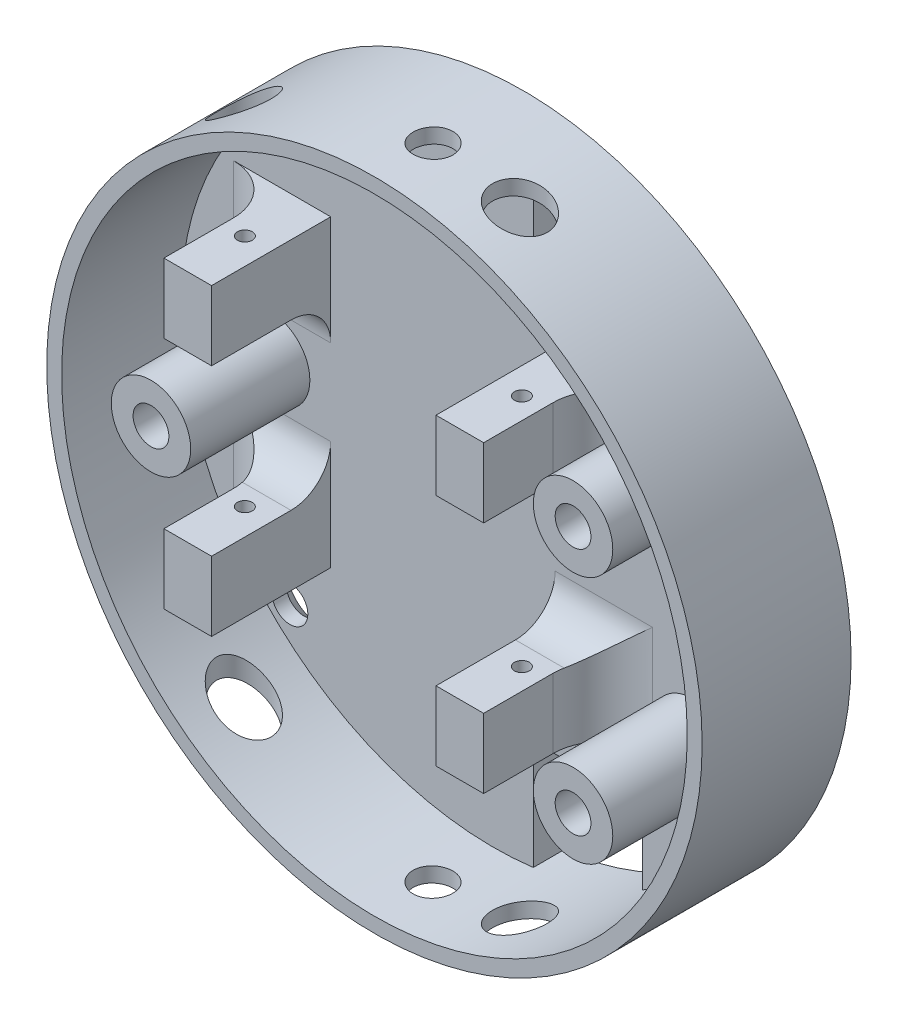
from build123d import *

# Parameters (mm, degrees)
CROQUIS1_R                                           = 33
SALIENTE_EXTRUIR1_DEPTH                              = 3
SALIENTE_EXTRUIR2_DEPTH                              = 12
CORTAR_EXTRUIR1_REACH                                = 62.389
CROQUIS3_R                                           = 0.7500000000000021
CROQUIS3_R_2                                         = 0.7500000000000004
CROQUIS6_R                                           = 1.8000000000000005
CROQUIS6_R_2                                         = 1.8000000000000007
CROQUIS6_R_3                                         = 1.8000000000011862
CROQUIS6_R_4                                         = 1.8000000000016134
CROQUIS6_R_5                                         = 1.8000000000006053
CORTAR_EXTRUIR4_DEPTH                                = 3
CROQUIS7_R                                           = 33
CROQUIS7_R_2                                         = 31.5
SALIENTE_EXTRUIR3_DEPTH                              = 12
CROQUIS8_R                                           = 2.75
CROQUIS8_R_2                                         = 2.7499999999999982
CROQUIS8_R_3                                         = 2
CORTAR_EXTRUIR5_DEPTH                                = 13.999999999999964
CROQUIS9_R                                           = 3.999999999999999
CROQUIS9_R_2                                         = 1.8000000000000007
CROQUIS9_R_3                                         = 1.8000000000000005
SALIENTE_EXTRUIR4_DEPTH                              = 12
CUT_EXTRUDE1_DEPTH                                   = 0.5
AVELLANADO_PARA_TORNILLO_CON_CABEZA_PLAN_D           = 3.6
AVELLANADO_PARA_TORNILLO_CON_CABEZA_PLAN_CSINK_D     = 6.3
AVELLANADO_PARA_TORNILLO_CON_CABEZA_PLAN_CSINK_ANGLE = 90
FILLET5_R                                            = 4
FILLET6_R                                            = 5
CUT_EXTRUDE4_DEPTH                                   = 3
CUT_EXTRUDE5_DEPTH                                   = 0.4
REFRENTADO_PARA_TORNILLO_TAP_N_CON_CABEZ_D           = 3.6
REFRENTADO_PARA_TORNILLO_TAP_N_CON_CABEZ_DEPTH       = 15
REFRENTADO_PARA_TORNILLO_TAP_N_CON_CABEZ_CSINK_D     = 6.72
REFRENTADO_PARA_TORNILLO_TAP_N_CON_CABEZ_CSINK_ANGLE = 90


with BuildPart() as part:
    # Croquis1 → Saliente-Extruir1 (new body)
    with BuildSketch(Plane.XY):
        Circle(CROQUIS1_R)
    extrude(amount=SALIENTE_EXTRUIR1_DEPTH)

    # Croquis2 → Saliente-Extruir2 (add)
    with BuildSketch(Plane.XY.offset(3)):
        Polygon((10.999999999999996, -8.299999999999999), (10.999999999999995, -15.299999999999997), (6.199999999999995, -15.299999999999999), (6.199999999999994, -8.299999999999999), align=None)
        Polygon((-16.40000000000001, -8.3), (-16.400000000000006, -15.300000000000002), (-21.200000000000003, -15.299999999999999), (-21.199999999999996, -8.299999999999999), align=None)
        Polygon((-21.200000000000003, 15.299999999999999), (-21.199999999999996, 8.299999999999999), (-16.40000000000001, 8.3), (-16.400000000000006, 15.300000000000002), align=None)
        Polygon((10.999999999999995, 15.299999999999997), (6.199999999999992, 15.299999999999997), (6.199999999999991, 8.299999999999999), (10.999999999999996, 8.299999999999999), align=None)
    extrude(amount=SALIENTE_EXTRUIR2_DEPTH)

    # Cortar-Extruir1: up to this face of the body (flat: up to its plane)
    cortar_extruir1_end = Plane(part.part.faces().sort_by_distance((8.6, 15.3, 9))[0])
    # Croquis3 → Cortar-Extruir1 (cut, up to the picked face)
    with BuildSketch(Plane.XZ.offset(15.300000000000015), mode=Mode.PRIVATE) as cortar_extruir1_sk1:
        with Locations(Location((-19.050000000000015, 9.000000000000002, 0), (0, 0, 270))):
            Circle(CROQUIS3_R)
    cortar_extruir1_tool1 = split(extrude(cortar_extruir1_sk1.sketch, amount=-CORTAR_EXTRUIR1_REACH, mode=Mode.PRIVATE), bisect_by=cortar_extruir1_end, keep=Keep.BOTH, mode=Mode.PRIVATE)
    # Croquis3 → Cortar-Extruir1 (cut, up to the picked face)
    with BuildSketch(Plane.XZ.offset(15.300000000000015), mode=Mode.PRIVATE) as cortar_extruir1_sk2:
        with Locations(Location((8.849999999999996, 9.000000000000002, 0), (0, 0, 270))):
            Circle(CROQUIS3_R_2)
    cortar_extruir1_tool2 = split(extrude(cortar_extruir1_sk2.sketch, amount=-CORTAR_EXTRUIR1_REACH, mode=Mode.PRIVATE), bisect_by=cortar_extruir1_end, keep=Keep.BOTH, mode=Mode.PRIVATE)
    add(cortar_extruir1_tool1.solids().sort_by(Axis((-19.05, -15.3, 9), (0, 1, 0)))[0], mode=Mode.SUBTRACT)
    add(cortar_extruir1_tool2.solids().sort_by(Axis((8.85, -15.3, 9), (0, 1, 0)))[0], mode=Mode.SUBTRACT)

    # Croquis6 → Cortar-Extruir4 (cut)
    with BuildSketch(Plane(origin=(0, 0, 0), x_dir=(-1, 0, 0), z_dir=(0, 0, -1))):
        with Locations((-20, 12.5)):
            Circle(CROQUIS6_R)
        with Locations((-19.999999999999996, -12.5)):
            Circle(CROQUIS6_R)
        with Locations((22.5, 3e-17)):
            Circle(CROQUIS6_R_2)
        with Locations((-20.506096654409923, 20.506096654409838)):
            Circle(CROQUIS6_R)
        with Locations((20.506096654409834, 20.506096654411067)):
            Circle(CROQUIS6_R_3)
        with Locations((20.506096654411067, -20.506096654408687)):
            Circle(CROQUIS6_R_4)
        with Locations((-20.50609665440869, -20.506096654409927)):
            Circle(CROQUIS6_R_5)
    extrude(amount=-CORTAR_EXTRUIR4_DEPTH, mode=Mode.SUBTRACT)

    # Croquis7 → Saliente-Extruir3 (add)
    with BuildSketch(Plane.XY.offset(3)):
        Circle(CROQUIS7_R)
        Circle(CROQUIS7_R_2, mode=Mode.SUBTRACT)
    extrude(amount=SALIENTE_EXTRUIR3_DEPTH)

    # Croquis8 → Cortar-Extruir5 (cut)
    with BuildSketch(Plane(origin=(1.193e-14, -33, 0), x_dir=(-1, 0, 0), z_dir=(0, -1, 0))):
        with Locations(Location((-8.75, -9.099999999999998, 0), (0, 0, 90))):
            Circle(CROQUIS8_R)
        with Locations(Location((19.050000000000004, -9.099999999999998, 0), (0, 0, 90))):
            Circle(CROQUIS8_R_2)
        with Locations(Location((0, -9.099999999999998, 0), (0, 0, 90))):
            Circle(CROQUIS8_R_3)
    cortar_extruir5 = extrude(amount=-CORTAR_EXTRUIR5_DEPTH, mode=Mode.SUBTRACT)

    # Croquis9 → Saliente-Extruir4 (add)
    # profile 1 of 3: a face of its own
    with BuildSketch(Plane.XY.offset(3)):
        with Locations((-22.5, 3e-17)):
            Circle(CROQUIS9_R)
        with Locations(Location((-22.5, 3e-17, 0), (0, 0, 180))):
            Circle(CROQUIS9_R_2, mode=Mode.SUBTRACT)
    # profile 2 of 3: a face of its own
    with BuildSketch(Plane.XY.offset(3)):
        with Locations((19.999999999999996, -12.5)):
            Circle(CROQUIS9_R)
        with Locations(Location((19.999999999999996, -12.5, 0), (0, 0, 180))):
            Circle(CROQUIS9_R_3, mode=Mode.SUBTRACT)
    # profile 3 of 3: a face of its own
    with BuildSketch(Plane.XY.offset(3)):
        with Locations((20, 12.5)):
            Circle(CROQUIS9_R)
        with Locations(Location((20, 12.5, 0), (0, 0, 180))):
            Circle(CROQUIS9_R_3, mode=Mode.SUBTRACT)
    extrude(amount=SALIENTE_EXTRUIR4_DEPTH)

    # Sketch3 → Cut-Extrude1 (cut)
    with BuildSketch(Plane(origin=(0, 0, 0), x_dir=(-1, 0, 0), z_dir=(0, 0, -1))):
        Polygon((4.1000000000000005, -7.6000000000000005), (-4.099999999999999, -7.600000000000002), (-4.099999999999999, 7.599999999999997), (4.1000000000000005, 7.599999999999999), align=None)
    extrude(amount=-CUT_EXTRUDE1_DEPTH, mode=Mode.SUBTRACT)

    # Avellanado para tornillo con cabeza plana de M31 (through all)
    with Locations(Plane(origin=(0, 0, 0), x_dir=(-1, 0, 0), z_dir=(0, 0, -1))):
        with Locations((-20, 12.5), (-20, -12.5), (22.5, 0)):
            CounterSinkHole(AVELLANADO_PARA_TORNILLO_CON_CABEZA_PLAN_D / 2, AVELLANADO_PARA_TORNILLO_CON_CABEZA_PLAN_CSINK_D / 2, counter_sink_angle=AVELLANADO_PARA_TORNILLO_CON_CABEZA_PLAN_CSINK_ANGLE)

    # Mirror1: Cortar-Extruir5 across plane
    add(cortar_extruir5.mirror(Plane.ZX), mode=Mode.SUBTRACT)

    # Fillet5
    fillet5_edges = [part.edges().sort_by_distance(p)[0] for p in [
        (8.599999999999994, -8.299999999999999, 3),
        (-18.800000000000004, -8.3, 3),
        (-18.800000000000004, 8.3, 3),
        (8.599999999999994, 8.299999999999999, 3),
    ]]
    fillet(fillet5_edges, radius=FILLET5_R)

    # Fillet6
    fillet6_edges = [part.edges().sort_by_distance(p)[0] for p in [
        (-21.199999999999996, 9.8, 2.9999999999999996),
        (-21.199999999999996, -9.799999999999999, 2.9999999999999996),
        (10.999999999999996, 9.799999999999999, 2.9999999999999996),
        (10.999999999999996, -9.799999999999997, 2.9999999999999996),
    ]]
    fillet(fillet6_edges, radius=FILLET6_R)

    # Sketch9 → Cut-Extrude4 (cut)
    with BuildSketch(Plane(origin=(0, 0, 0), x_dir=(-1, 0, 0), z_dir=(0, 0, -1))):
        with BuildLine():
            Line((-4.000000000000002, -31.244999599935987), (-4.000000000000002, -20.244999599935987))
            Line((-4.000000000000002, -20.244999599935987), (-7.000000000000003, -20.244999599935987))
            Line((-7.000000000000003, -20.244999599935987), (-7.000000000000003, -22.79927796892908))
            Line((-7.000000000000003, -22.79927796892908), (-15, -22.799277968929083))
            Line((-15, -22.799277968929083), (-15, -27.699277968929085))
            ThreePointArc((-15, -27.699277968929085), (-9.66400721601281, -29.980943356219672), (-4.000000000000002, -31.244999599935987))
        make_face()
    cut_extrude4 = extrude(amount=-CUT_EXTRUDE4_DEPTH, mode=Mode.SUBTRACT)

    # Sketch10 → Cut-Extrude5 (cut)
    with BuildSketch(Plane(origin=(0, 0, 0), x_dir=(-1, 0, 0), z_dir=(0, 0, -1))):
        Polygon((-4.000000000000002, -22.79927796892908), (3.099999999999997, -22.79927796892908), (3.0999999999999988, -30.899277968929077), (-4.000000000000001, -30.899277968929077), align=None)
        Polygon((3.099999999999991, 22.79927796892908), (3.099999999999991, 30.899277968929077), (-4.000000000000009, 30.899277968929077), (-4.000000000000007, 22.79927796892908), align=None)
    extrude(amount=-CUT_EXTRUDE5_DEPTH, mode=Mode.SUBTRACT)

    # Mirror3: Cut-Extrude4 across plane
    add(cut_extrude4.mirror(Plane.ZX), mode=Mode.SUBTRACT)

    # Refrentado para tornillo tapón con cabeza plana de clavija de M31
    with Locations(Plane(origin=(0, 0, 0), x_dir=(-1, 0, 0), z_dir=(0, 0, -1))):
        with Locations((-20.506096654, -20.506096654), (20.506096654, -20.506096654), (20.506096654, 20.506096654), (-20.506096654, 20.506096654)):
            CounterSinkHole(REFRENTADO_PARA_TORNILLO_TAP_N_CON_CABEZ_D / 2, REFRENTADO_PARA_TORNILLO_TAP_N_CON_CABEZ_CSINK_D / 2, depth=REFRENTADO_PARA_TORNILLO_TAP_N_CON_CABEZ_DEPTH, counter_sink_angle=REFRENTADO_PARA_TORNILLO_TAP_N_CON_CABEZ_CSINK_ANGLE)


solid = part.part
